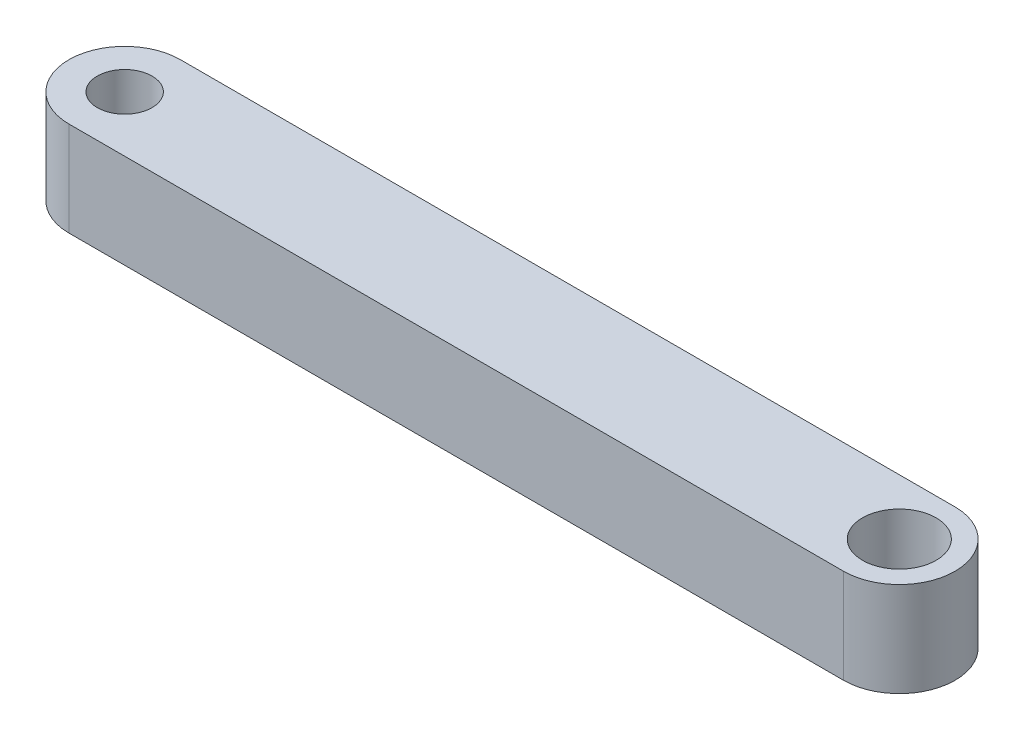
from build123d import *

# Parameters (mm, degrees)
SKETCH1_R           = 1.95
SKETCH1_R_2         = 1.45
BOSS_EXTRUDE1_DEPTH = 5


with BuildPart() as part:
    # Sketch1 → Boss-Extrude1 (new body)
    with BuildSketch(Plane.XZ):
        with BuildLine():
            Line((32, 2.95), (-9, 2.95))
            ThreePointArc((-9, 2.95), (-11.95, 0), (-9, -2.95))
            Line((-9, -2.95), (32, -2.95))
            ThreePointArc((32, -2.95), (34.95, 0), (32, 2.95))
        make_face()
        with Locations((32, 0)):
            Circle(SKETCH1_R, mode=Mode.SUBTRACT)
        with Locations((-9, 0)):
            Circle(SKETCH1_R_2, mode=Mode.SUBTRACT)
    extrude(amount=-BOSS_EXTRUDE1_DEPTH)


solid = part.part
